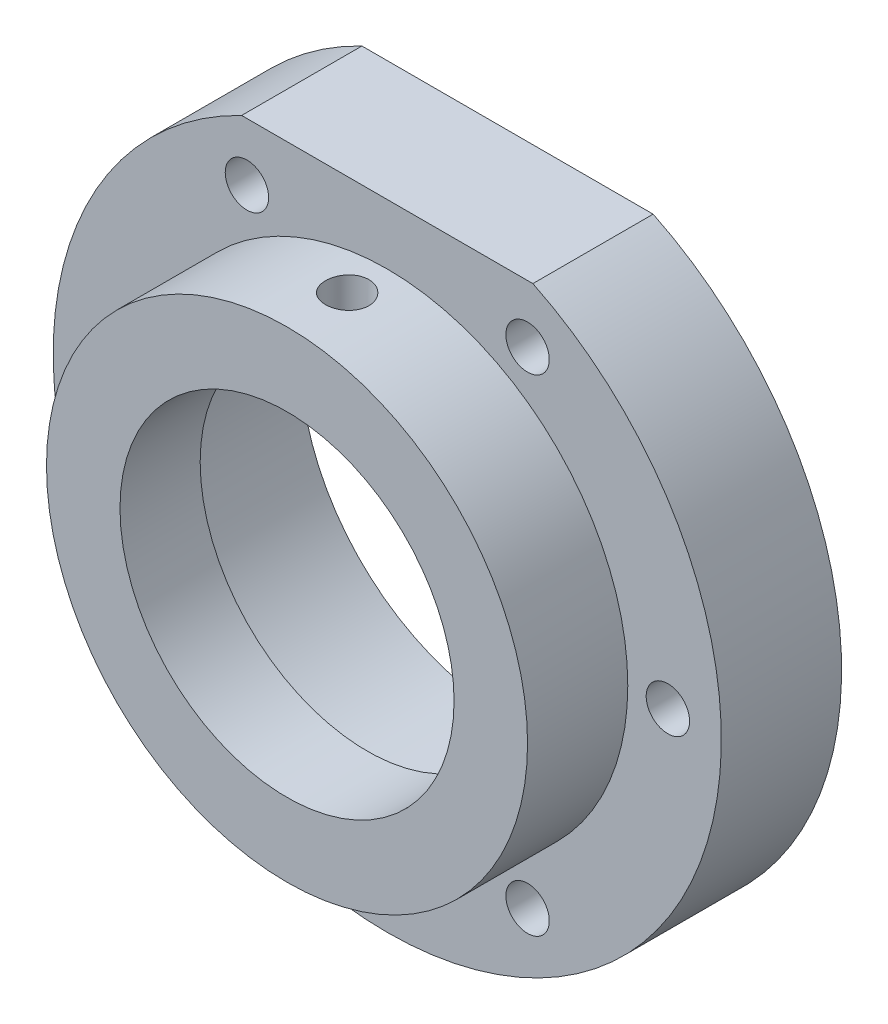
from build123d import *

# Parameters (mm, degrees)
SALIENTE_EXTRUIR1_DEPTH = 18
CROQUIS2_R              = 36
SALIENTE_EXTRUIR2_DEPTH = 15
CROQUIS3_R              = 31
CORTAR_EXTRUIR1_DEPTH   = 21
CROQUIS4_R              = 25
CORTAR_EXTRUIR2_DEPTH   = 21
CROQUIS5_R              = 3.25
CORTAR_EXTRUIR3_DEPTH   = 21
MATRIZC1_COUNT          = 6
CROQUIS6_R              = 5
CORTAR_EXTRUIR4_DEPTH   = 6
MATRIZC2_COUNT          = 6
CROQUIS7_R              = 3.25
CORTAR_EXTRUIR5_DEPTH   = 27


with BuildPart() as part:
    # Croquis1 → Saliente-Extruir1 (new body)
    with BuildSketch(Plane.XY):
        with BuildLine():
            Line((-21.794494718, 45), (21.794494718, 45))
            ThreePointArc((21.794494718, 45), (0, -50), (-21.794494718, 45))
        make_face()
    extrude(amount=SALIENTE_EXTRUIR1_DEPTH)

    # Croquis2 → Saliente-Extruir2 (add)
    with BuildSketch(Plane.XY.offset(18)):
        Circle(CROQUIS2_R)
    extrude(amount=SALIENTE_EXTRUIR2_DEPTH)

    # Croquis3 → Cortar-Extruir1 (cut)
    with BuildSketch(Plane(origin=(0, 0, 0), x_dir=(-1, 0, 0), z_dir=(0, 0, -1))):
        Circle(CROQUIS3_R)
    extrude(amount=-CORTAR_EXTRUIR1_DEPTH, mode=Mode.SUBTRACT)

    # Croquis4 → Cortar-Extruir2 (cut)
    with BuildSketch(Plane(origin=(0, 0, 21), x_dir=(-1, 0, 0), z_dir=(0, 0, -1))):
        Circle(CROQUIS4_R)
    extrude(amount=-CORTAR_EXTRUIR2_DEPTH, mode=Mode.SUBTRACT)

    # Croquis5 → Cortar-Extruir3 (cut)
    with BuildSketch(Plane(origin=(0, 0, 0), x_dir=(-1, 0, 0), z_dir=(0, 0, -1))):
        with Locations((-42, 0)):
            Circle(CROQUIS5_R)
    cortar_extruir3 = extrude(amount=-CORTAR_EXTRUIR3_DEPTH, mode=Mode.SUBTRACT)

    # MatrizC1: Cortar-Extruir3 ×6 about axis
    matrizc1_axis = Axis((0, 0, 0), (0, 0, 1))
    for i in range(1, MATRIZC1_COUNT):
        add(cortar_extruir3.rotate(matrizc1_axis, i * 360 / MATRIZC1_COUNT), mode=Mode.SUBTRACT)

    # Croquis6 → Cortar-Extruir4 (cut)
    with BuildSketch(Plane(origin=(0, 0, 0), x_dir=(-1, 0, 0), z_dir=(0, 0, -1))):
        with Locations((-21, 36.373066959)):
            Circle(CROQUIS6_R)
    cortar_extruir4 = extrude(amount=-CORTAR_EXTRUIR4_DEPTH, mode=Mode.SUBTRACT)

    # MatrizC2: Cortar-Extruir4 ×6 about axis
    matrizc2_axis = Axis((0, 0, 0), (0, 0, 1))
    for i in range(1, MATRIZC2_COUNT):
        add(cortar_extruir4.rotate(matrizc2_axis, i * 360 / MATRIZC2_COUNT), mode=Mode.SUBTRACT)

    # Croquis7 → Cortar-Extruir5 (cut)
    with BuildSketch(Plane(origin=(0, 45, 0), x_dir=(1, 0, 0), z_dir=(0, 1, 0))):
        with Locations((0, -24)):
            Circle(CROQUIS7_R)
    extrude(amount=-CORTAR_EXTRUIR5_DEPTH, mode=Mode.SUBTRACT)


solid = part.part
